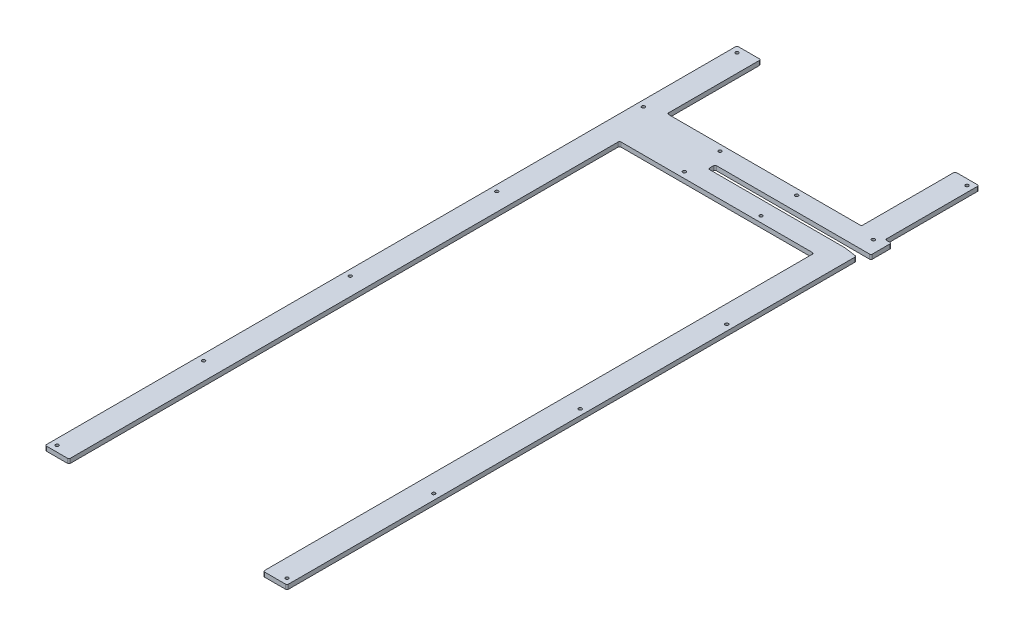
from build123d import *

# Parameters (mm, degrees)
BOSS_EXTRUDE1_DEPTH                                 = 9.525
SKETCH4_W                                           = 50.8
SKETCH4_H                                           = 200
BOSS_EXTRUDE2_DEPTH                                 = 9.525
CSK_FOR_1_4_FLAT_HEAD_MACHINE_SCREW_100_D           = 6.7564
CSK_FOR_1_4_FLAT_HEAD_MACHINE_SCREW_100_CSINK_D     = 17.6447958
CSK_FOR_1_4_FLAT_HEAD_MACHINE_SCREW_100_CSINK_ANGLE = 100
LPATTERN3_COUNT                                     = 2
LPATTERN3_PITCH                                     = 491.2
LPATTERN3_COUNT_DIR2                                = 5
LPATTERN3_PITCH_DIR2                                = 313.05
LPATTERN2_COUNT                                     = 3
LPATTERN2_PITCH                                     = 163.733333333
LPATTERN2_COUNT_DIR2                                = 2
LPATTERN2_PITCH_DIR2                                = 76.2
CSK_FOR_1_4_FLAT_HEAD_MACHINE_SCREW_2_D             = 6.7564
CSK_FOR_1_4_FLAT_HEAD_MACHINE_SCREW_2_CSINK_D       = 17.6447958
CSK_FOR_1_4_FLAT_HEAD_MACHINE_SCREW_2_CSINK_ANGLE   = 100
FILLET1_R                                           = 3.175
FILLET2_R                                           = 3.175


with BuildPart() as part:
    # Sketch1 → Boss-Extrude1 (new body)
    with BuildSketch(Plane(origin=(0, 0, 0), x_dir=(1, 0, 0), z_dir=(0, 1, 0))):
        Polygon((-258.3, 0), (-207.5, 0), (-207.5, 1176), (207.5, 1176), (207.5, 0), (258.3, 0), (258.3, 1215.514856628), (230.3, 1219.45), (-61.7, 1219.45), (-61.7, 1234.15), (271.3, 1234.15), (271.3, 1277.6), (-258.3, 1277.6), align=None)
    extrude(amount=BOSS_EXTRUDE1_DEPTH)

    # Sketch4 → Boss-Extrude2 (add)
    with BuildSketch(Plane.XZ):
        with Locations((-232.9, -1377.6)):
            Rectangle(SKETCH4_W, SKETCH4_H)
        with Locations((232.9, -1377.6)):
            Rectangle(SKETCH4_W, SKETCH4_H)
    extrude(amount=-BOSS_EXTRUDE2_DEPTH)

    # CSK for 1_4 Flat Head Machine Screw _100 (through all)
    with Locations(Plane.XZ):
        with Locations((-245.6, -1264.9)):
            csk_for_1_4_flat_head_machine_screw_100 = CounterSinkHole(CSK_FOR_1_4_FLAT_HEAD_MACHINE_SCREW_100_D / 2, CSK_FOR_1_4_FLAT_HEAD_MACHINE_SCREW_100_CSINK_D / 2, counter_sink_angle=CSK_FOR_1_4_FLAT_HEAD_MACHINE_SCREW_100_CSINK_ANGLE)

    # LPattern3: CSK for 1_4 Flat Head Machine Screw _100 2 × 5
    with Locations(*[(i * LPATTERN3_PITCH, 0, j * LPATTERN3_PITCH_DIR2) for i in range(LPATTERN3_COUNT) for j in range(LPATTERN3_COUNT_DIR2) if (i, j) != (0, 0)]):
        add(csk_for_1_4_flat_head_machine_screw_100, mode=Mode.SUBTRACT)

    # LPattern2: CSK for 1_4 Flat Head Machine Screw _100 3 × 2, 1 skipped
    with Locations(*[(i * LPATTERN2_PITCH, 0, j * LPATTERN2_PITCH_DIR2) for i in range(LPATTERN2_COUNT) for j in range(LPATTERN2_COUNT_DIR2) if (i, j) not in ((0, 0), (0, 1))]):
        add(csk_for_1_4_flat_head_machine_screw_100, mode=Mode.SUBTRACT)

    # CSK for 1_4 Flat Head Machine Screw  2 (through all)
    with Locations(Plane.XZ):
        with Locations((-245.6, -1464.9)):
            csk_for_1_4_flat_head_machine_screw_2 = CounterSinkHole(CSK_FOR_1_4_FLAT_HEAD_MACHINE_SCREW_2_D / 2, CSK_FOR_1_4_FLAT_HEAD_MACHINE_SCREW_2_CSINK_D / 2, counter_sink_angle=CSK_FOR_1_4_FLAT_HEAD_MACHINE_SCREW_2_CSINK_ANGLE)

    # Mirror1: CSK for 1_4 Flat Head Machine Screw  2 across plane
    add(csk_for_1_4_flat_head_machine_screw_2.mirror(Plane(origin=(0, 0, 0), x_dir=(0, 0, 1), z_dir=(1, 0, 0))), mode=Mode.SUBTRACT)

    # Fillet1
    fillet1_edges = [part.edges().sort_by_distance(p)[0] for p in [
        (258.3, 4.7625, 0),
        (207.5, 4.7625, 0),
        (-207.5, 4.7625, 0),
        (-258.3, 4.7625, 0),
        (207.5, 4.7625, -1176),
        (-207.5, 4.7625, -1176),
        (258.3, 4.7625, -1215.514856628),
        (271.3, 4.7625, -1234.15),
        (271.3, 4.7625, -1277.6),
        (-61.7, 4.7625, -1219.45),
        (-61.7, 4.7625, -1234.15),
    ]]
    fillet(fillet1_edges, radius=FILLET1_R)

    # Fillet2
    fillet2_edges = [part.edges().sort_by_distance(p)[0] for p in [
        (207.5, 4.7625, -1477.6),
        (258.3, 4.7625, -1477.6),
        (-258.3, 4.7625, -1477.6),
        (-207.5, 4.7625, -1477.6),
        (-207.5, 4.7625, -1277.6),
        (207.5, 4.7625, -1277.6),
        (258.3, 4.7625, -1277.6),
    ]]
    fillet(fillet2_edges, radius=FILLET2_R)


solid = part.part
